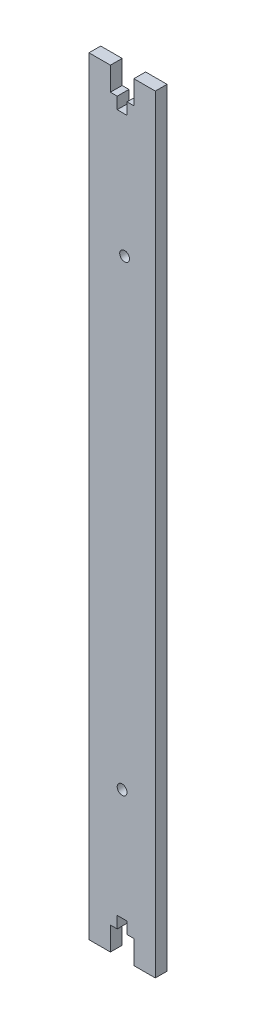
from build123d import *

# Parameters (mm, degrees)
SKETCH1_W           = 28.28
SKETCH1_H           = 327.5
BOSS_EXTRUDE1_DEPTH = 5
SKETCH2_R           = 2.1
CUT_EXTRUDE1_DEPTH  = 10
SKETCH3_R           = 2.1
CUT_EXTRUDE2_DEPTH  = 10


with BuildPart() as part:
    # Sketch1 → Boss-Extrude1 (new body)
    with BuildSketch(Plane.XY):
        Rectangle(SKETCH1_W, SKETCH1_H)
    extrude(amount=BOSS_EXTRUDE1_DEPTH)

    # Sketch2 → Cut-Extrude1 (cut)
    with BuildSketch(Plane.XY.offset(5)):
        with Locations((1.058524548, 96.25)):
            Circle(SKETCH2_R)
        Polygon((5, 163.75), (5, 153.75), (2.1, 153.75), (2.1, 148.75), (-2.1, 148.75), (-2.1, 153.75), (-5, 153.75), (-5, 163.75), align=None)
        Polygon((2.1, -148.75), (-2.1, -148.75), (-2.1, -153.75), (-5, -153.75), (-5, -163.75), (5, -163.75), (5, -153.75), (2.1, -153.75), align=None)
    extrude(amount=-CUT_EXTRUDE1_DEPTH, mode=Mode.SUBTRACT)

    # Sketch3 → Cut-Extrude2 (cut)
    with BuildSketch(Plane.XY.offset(5)):
        with Locations((-0.002135624, -101.25)):
            Circle(SKETCH3_R)
    extrude(amount=-CUT_EXTRUDE2_DEPTH, mode=Mode.SUBTRACT)


solid = part.part
